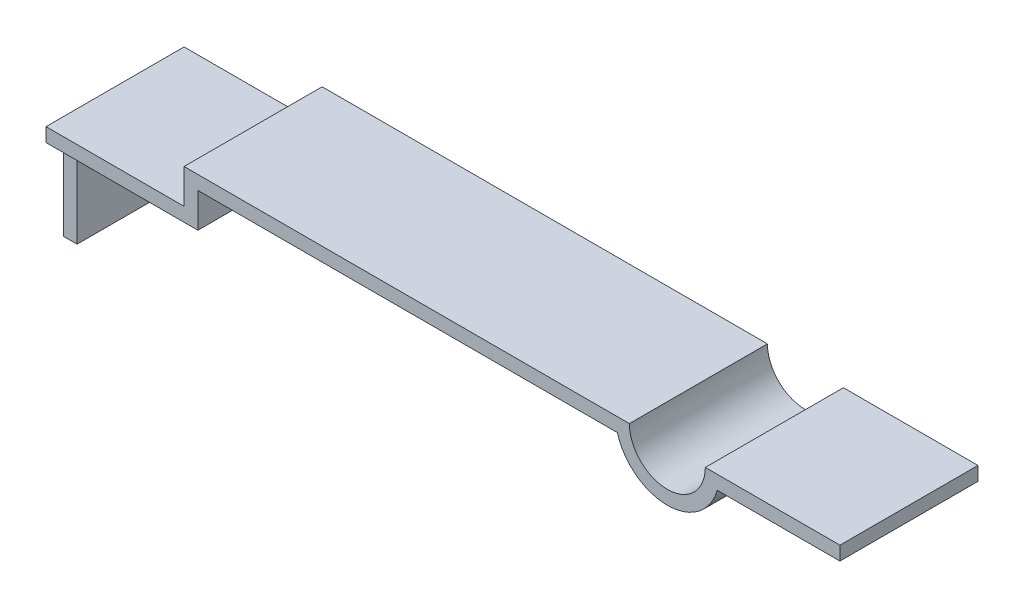
from build123d import *

# Parameters (mm, degrees)
EXTRUDE_1_DEPTH     = 2
SKETCH_3_W          = 0.25
SKETCH_3_H          = 1.3
CUT_EXTRUDE_2_DEPTH = 1.2


with BuildPart() as part:
    # 草图1 → 凸台-拉伸1 (new body)
    with BuildSketch(Plane.XY):
        with BuildLine():
            Line((0, 0), (0, 0.5))
            Line((0, 0.5), (6.45, 0.5))
            ThreePointArc((6.45, 0.5), (7, -0.05), (7.55, 0.5))
            Line((7.55, 0.5), (9.5, 0.5))
            Line((9.5, 0.5), (9.5, 0.3))
            Line((9.5, 0.3), (7.722841615, 0.3))
            ThreePointArc((7.722841615, 0.3), (7, -0.25), (6.277158385, 0.3))
            Line((6.277158385, 0.3), (0.2, 0.3))
            Line((0.2, 0.3), (0.2, -0.2))
            Line((0.2, -0.2), (-1.8, -0.2))
            Line((-1.8, -0.2), (-1.8, -1.5))
            Line((-1.8, -1.5), (-2, -1.5))
            Line((-2, -1.5), (-2, 0))
            Line((-2, 0), (0, 0))
        make_face()
    extrude(amount=EXTRUDE_1_DEPTH)

    # 草图3 → 切除-拉伸2 (cut, through all)
    with BuildSketch(Plane(origin=(-1.8, 0, 0), x_dir=(0, 0, -1), z_dir=(1, 0, 0))):
        with Locations((-1.875, -0.85)):
            Rectangle(SKETCH_3_W, SKETCH_3_H)
        with Locations((-0.125, -0.85)):
            Rectangle(SKETCH_3_W, SKETCH_3_H)
    extrude(amount=-CUT_EXTRUDE_2_DEPTH, mode=Mode.SUBTRACT)


solid = part.part
